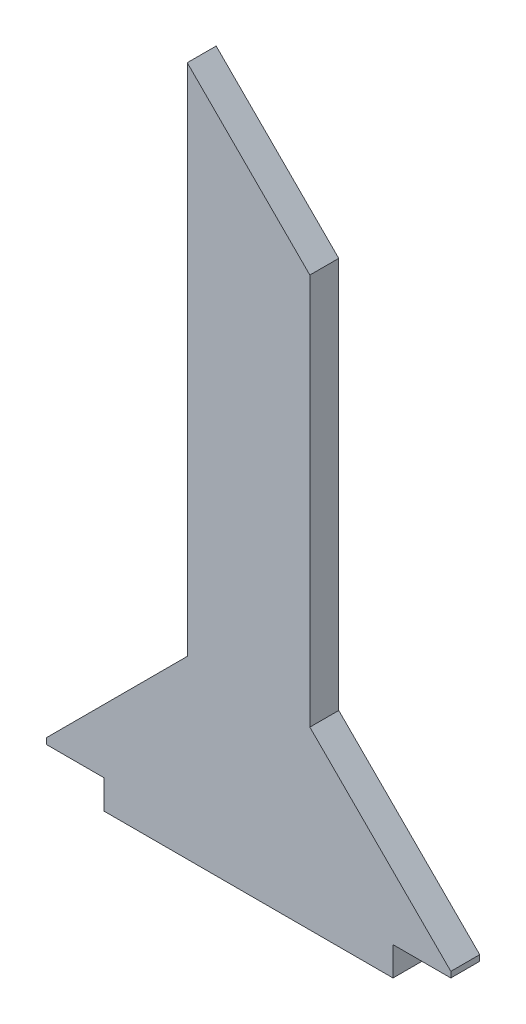
from build123d import *

# Parameters (mm, degrees)
BOSS_EXTRUDE1_DEPTH = 20


with BuildPart() as part:
    # Sketch1 → Boss-Extrude1 (new body)
    with BuildSketch(Plane.XY):
        Polygon((150, -163.786796564), (350, -163.786796564), (350, -143.786796564), (390, -143.786796564), (390, -139.786796564), (292.426406871, -42.213203436), (292.426406871, 228.786796564), (207.573593129, 313.639610307), (207.573593129, -42.213203436), (110, -139.786796564), (110, -143.786796564), (150, -143.786796564), align=None)
    extrude(amount=BOSS_EXTRUDE1_DEPTH)


solid = part.part
